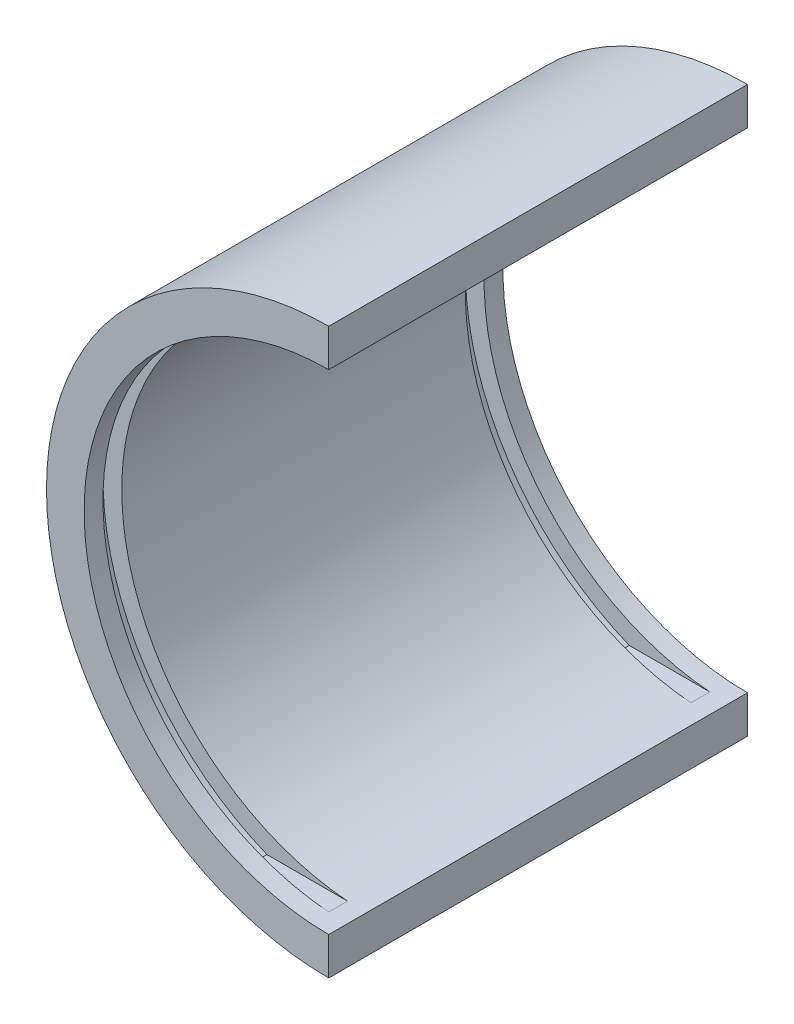
from build123d import *

# Parameters (mm, degrees)
BOSS_EXTRUDE1_DEPTH = 222.57
CUT_EXTRUDE2_START  = -10
CUT_EXTRUDE2_DEPTH  = 10
CUT_EXTRUDE3_START  = -10
CUT_EXTRUDE3_DEPTH  = 10


with BuildPart() as part:
    # Sketch1 → Boss-Extrude1 (new body)
    with BuildSketch(Plane.XY):
        with BuildLine():
            Line((0, 150), (0, 130))
            ThreePointArc((0, 130), (-130, 0), (0, -130))
            Line((0, -130), (0, -150))
            ThreePointArc((0, -150), (-150, 0), (0, 150))
        make_face()
    extrude(amount=BOSS_EXTRUDE1_DEPTH)

    # Sketch2 → Cut-Extrude2 (cut)
    with BuildSketch(Plane.XY.offset(222.57).offset(CUT_EXTRUDE2_START)):
        with BuildLine():
            Line((-10, 129.614813968), (-52.842182765, 129.614813968))
            ThreePointArc((-52.842182765, 129.614813968), (-139.972484008, 0), (-52.842182765, -129.614813968))
            Line((-52.842182765, -129.614813968), (-10, -129.614813968))
            ThreePointArc((-10, -129.614813968), (-130, 0), (-10, 129.614813968))
        make_face()
    extrude(amount=-CUT_EXTRUDE2_DEPTH, mode=Mode.SUBTRACT)

    # Sketch3 → Cut-Extrude3 (cut)
    with BuildSketch(Plane(origin=(0, 0, 0), x_dir=(-1, 0, 0), z_dir=(0, 0, -1)).offset(CUT_EXTRUDE3_START)):
        with BuildLine():
            Line((10, 129.614813968), (52.842182765, 129.614813968))
            ThreePointArc((52.842182765, 129.614813968), (139.972484008, 0), (52.842182765, -129.614813968))
            Line((52.842182765, -129.614813968), (10, -129.614813968))
            ThreePointArc((10, -129.614813968), (130, 0), (10, 129.614813968))
        make_face()
    extrude(amount=-CUT_EXTRUDE3_DEPTH, mode=Mode.SUBTRACT)


solid = part.part
